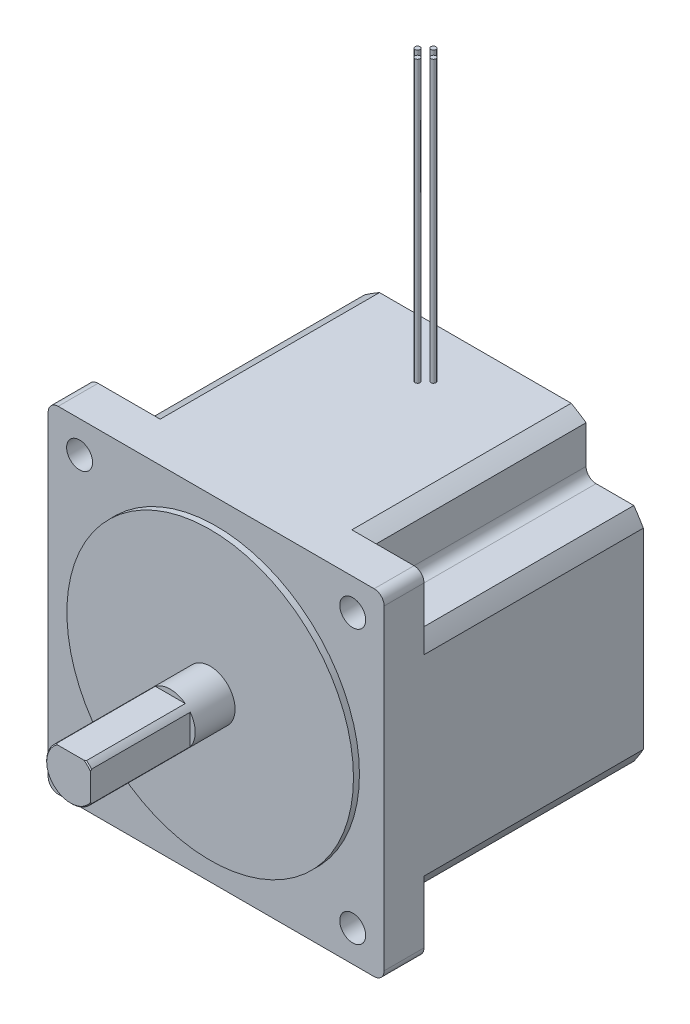
from build123d import *

# Parameters (mm, degrees)
SKETCH1_W           = 85.598
SKETCH1_H           = 85.598
BOSS_EXTRUDE1_DEPTH = 66.04
CUT_EXTRUDE1_DEPTH  = 55.88
CUT_EXTRUDE2_DEPTH  = 55.88
CUT_EXTRUDE3_DEPTH  = 55.88
CUT_EXTRUDE4_DEPTH  = 55.88
CUT_EXTRUDE5_DEPTH  = 55.88
CUT_EXTRUDE6_DEPTH  = 55.88
CUT_EXTRUDE7_DEPTH  = 55.88
CUT_EXTRUDE8_DEPTH  = 55.88
SKETCH10_R          = 36.5125
BOSS_EXTRUDE2_DEPTH = 1.524
SKETCH11_R          = 6.35
BOSS_EXTRUDE3_DEPTH = 35.56
CUT_EXTRUDE9_DEPTH  = 25.4
CUT_EXTRUDE10_DEPTH = 25.4
SKETCH14_W          = 0.635
SKETCH14_H          = 71.501
SKETCH15_W          = 0.635
SKETCH15_H          = 71.501
SKETCH16_W          = 0.635
SKETCH16_H          = 71.501
SKETCH17_W          = 0.635
SKETCH17_H          = 71.501
HOLE1_D             = 6.604
HOLE1_DEPTH         = 47.244
HOLE2_D             = 6.604
HOLE2_DEPTH         = 47.244
HOLE3_D             = 6.604
HOLE3_DEPTH         = 47.244
HOLE4_D             = 6.604
HOLE4_DEPTH         = 47.244
CHAMFER1_SIZE       = 0.254
CHAMFER2_SIZE       = 0.254
FILLET1_R           = 2.54
FILLET2_R           = 2.54
FILLET3_R           = 2.54
FILLET4_R           = 2.54
FILLET5_R           = 2.54
FILLET6_R           = 2.54
FILLET7_R           = 2.54
FILLET8_R           = 2.54


with BuildPart() as part:
    # Sketch1 → Boss-Extrude1 (new body)
    with BuildSketch(Plane.XY.offset(66.04)):
        Rectangle(SKETCH1_W, SKETCH1_H)
    extrude(amount=-BOSS_EXTRUDE1_DEPTH)

    # Sketch2 → Cut-Extrude1 (cut)
    with BuildSketch(Plane(origin=(0, 0, 0), x_dir=(-1, 0, 0), z_dir=(0, 0, -1))):
        with BuildLine():
            Line((-42.799, -42.799), (-24.420683344, -42.799))
            ThreePointArc((-24.420683344, -42.799), (-34.84339375, -34.84339375), (-42.799, -24.420683344))
            Line((-42.799, -24.420683344), (-42.799, -42.799))
        make_face()
    extrude(amount=-CUT_EXTRUDE1_DEPTH, mode=Mode.SUBTRACT)

    # Sketch3 → Cut-Extrude2 (cut)
    with BuildSketch(Plane(origin=(0, 0, 0), x_dir=(-1, 0, 0), z_dir=(0, 0, -1))):
        with BuildLine():
            Line((-28.2194, -40.395416072), (-28.2194, -28.2194))
            Line((-28.2194, -28.2194), (-40.395416072, -28.2194))
            ThreePointArc((-40.395416072, -28.2194), (-34.84339375, -34.84339375), (-28.2194, -40.395416072))
        make_face()
    extrude(amount=-CUT_EXTRUDE2_DEPTH, mode=Mode.SUBTRACT)

    # Sketch4 → Cut-Extrude3 (cut)
    with BuildSketch(Plane(origin=(0, 0, 0), x_dir=(-1, 0, 0), z_dir=(0, 0, -1))):
        with BuildLine():
            Line((-42.799, 42.799), (-42.799, 24.420683344))
            ThreePointArc((-42.799, 24.420683344), (-34.84339375, 34.84339375), (-24.420683344, 42.799))
            Line((-24.420683344, 42.799), (-42.799, 42.799))
        make_face()
    extrude(amount=-CUT_EXTRUDE3_DEPTH, mode=Mode.SUBTRACT)

    # Sketch5 → Cut-Extrude4 (cut)
    with BuildSketch(Plane(origin=(0, 0, 0), x_dir=(-1, 0, 0), z_dir=(0, 0, -1))):
        with BuildLine():
            Line((-40.395416072, 28.2194), (-28.2194, 28.2194))
            Line((-28.2194, 28.2194), (-28.2194, 40.395416072))
            ThreePointArc((-28.2194, 40.395416072), (-34.84339375, 34.84339375), (-40.395416072, 28.2194))
        make_face()
    extrude(amount=-CUT_EXTRUDE4_DEPTH, mode=Mode.SUBTRACT)

    # Sketch6 → Cut-Extrude5 (cut)
    with BuildSketch(Plane(origin=(0, 0, 0), x_dir=(-1, 0, 0), z_dir=(0, 0, -1))):
        with BuildLine():
            Line((42.799, 42.799), (24.420683344, 42.799))
            ThreePointArc((24.420683344, 42.799), (34.84339375, 34.84339375), (42.799, 24.420683344))
            Line((42.799, 24.420683344), (42.799, 42.799))
        make_face()
    extrude(amount=-CUT_EXTRUDE5_DEPTH, mode=Mode.SUBTRACT)

    # Sketch7 → Cut-Extrude6 (cut)
    with BuildSketch(Plane(origin=(0, 0, 0), x_dir=(-1, 0, 0), z_dir=(0, 0, -1))):
        with BuildLine():
            Line((28.2194, 40.395416072), (28.2194, 28.2194))
            Line((28.2194, 28.2194), (40.395416072, 28.2194))
            ThreePointArc((40.395416072, 28.2194), (34.84339375, 34.84339375), (28.2194, 40.395416072))
        make_face()
    extrude(amount=-CUT_EXTRUDE6_DEPTH, mode=Mode.SUBTRACT)

    # Sketch8 → Cut-Extrude7 (cut)
    with BuildSketch(Plane(origin=(0, 0, 0), x_dir=(-1, 0, 0), z_dir=(0, 0, -1))):
        with BuildLine():
            Line((42.799, -42.799), (42.799, -24.420683344))
            ThreePointArc((42.799, -24.420683344), (34.84339375, -34.84339375), (24.420683344, -42.799))
            Line((24.420683344, -42.799), (42.799, -42.799))
        make_face()
    extrude(amount=-CUT_EXTRUDE7_DEPTH, mode=Mode.SUBTRACT)

    # Sketch9 → Cut-Extrude8 (cut)
    with BuildSketch(Plane(origin=(0, 0, 0), x_dir=(-1, 0, 0), z_dir=(0, 0, -1))):
        with BuildLine():
            Line((40.395416072, -28.2194), (28.2194, -28.2194))
            Line((28.2194, -28.2194), (28.2194, -40.395416072))
            ThreePointArc((28.2194, -40.395416072), (34.84339375, -34.84339375), (40.395416072, -28.2194))
        make_face()
    extrude(amount=-CUT_EXTRUDE8_DEPTH, mode=Mode.SUBTRACT)

    # Sketch10 → Boss-Extrude2 (add)
    with BuildSketch(Plane.XY.offset(66.04)):
        Circle(SKETCH10_R)
    extrude(amount=BOSS_EXTRUDE2_DEPTH)

    # Sketch11 → Boss-Extrude3 (add)
    with BuildSketch(Plane.XY.offset(67.564)):
        Circle(SKETCH11_R)
    extrude(amount=BOSS_EXTRUDE3_DEPTH)

    # Sketch12 → Cut-Extrude9 (cut)
    with BuildSketch(Plane.XY.offset(103.124)):
        with BuildLine():
            Line((-3.81, 5.08), (3.81, 5.08))
            ThreePointArc((3.81, 5.08), (0, 6.35), (-3.81, 5.08))
        make_face()
    extrude(amount=-CUT_EXTRUDE9_DEPTH, mode=Mode.SUBTRACT)

    # Sketch13 → Cut-Extrude10 (cut)
    with BuildSketch(Plane.XY.offset(103.124)):
        with BuildLine():
            Line((5.08, 3.81), (5.08, -3.81))
            ThreePointArc((5.08, -3.81), (6.35, 0), (5.08, 3.81))
        make_face()
    extrude(amount=-CUT_EXTRUDE10_DEPTH, mode=Mode.SUBTRACT)

    # Sketch14 → Revolve1 (revolve)
    with BuildSketch(Plane(origin=(0, 0, 12.7), x_dir=(-1, 0, 0), z_dir=(0, 0, -1))):
        with Locations((1.7145, 78.5495)):
            Rectangle(SKETCH14_W, SKETCH14_H)
    revolve(axis=Axis((-2.032, 42.799, 12.7), (0, 1, 0)))

    # Sketch15 → Revolve2 (revolve)
    with BuildSketch(Plane(origin=(0, 0, 12.7), x_dir=(-1, 0, 0), z_dir=(0, 0, -1))):
        with Locations((-2.3495, 78.5495)):
            Rectangle(SKETCH15_W, SKETCH15_H)
    revolve(axis=Axis((2.032, 42.799, 12.7), (0, 1, 0)))

    # Sketch16 → Revolve3 (revolve)
    with BuildSketch(Plane(origin=(0, 0, 14.732), x_dir=(-1, 0, 0), z_dir=(0, 0, -1))):
        with Locations((-0.3175, 78.5495)):
            Rectangle(SKETCH16_W, SKETCH16_H)
    revolve(axis=Axis((0, 42.799, 14.732), (0, 1, 0)))

    # Sketch17 → Revolve4 (revolve)
    with BuildSketch(Plane(origin=(0, 0, 10.668), x_dir=(-1, 0, 0), z_dir=(0, 0, -1))):
        with Locations((-0.3175, 78.5495)):
            Rectangle(SKETCH17_W, SKETCH17_H)
    revolve(axis=Axis((0, 42.799, 10.668), (0, 1, 0)))

    # Hole1
    with Locations(Plane(origin=(0, 0, 55.88), x_dir=(-1, 0, 0), z_dir=(0, 0, -1))):
        with Locations((34.798, -34.798)):
            Hole(HOLE1_D / 2, depth=HOLE1_DEPTH)

    # Hole2
    with Locations(Plane(origin=(0, 0, 55.88), x_dir=(-1, 0, 0), z_dir=(0, 0, -1))):
        with Locations((34.798, 34.798)):
            Hole(HOLE2_D / 2, depth=HOLE2_DEPTH)

    # Hole3
    with Locations(Plane(origin=(0, 0, 55.88), x_dir=(-1, 0, 0), z_dir=(0, 0, -1))):
        with Locations((-34.798, 34.798)):
            Hole(HOLE3_D / 2, depth=HOLE3_DEPTH)

    # Hole4
    with Locations(Plane(origin=(0, 0, 55.88), x_dir=(-1, 0, 0), z_dir=(0, 0, -1))):
        with Locations((-34.798, -34.798)):
            Hole(HOLE4_D / 2, depth=HOLE4_DEPTH)

    # Chamfer1
    chamfer1_edges = [part.edges().sort_by_distance(p)[0] for p in [
        (-4.490128061, -4.490128061, 103.124),
    ]]
    chamfer(chamfer1_edges, length=CHAMFER1_SIZE)

    # Chamfer2
    chamfer2_edges = [part.edges().sort_by_distance(p)[0] for p in [
        (4.490128061, 4.490128061, 103.124),
    ]]
    chamfer(chamfer2_edges, length=CHAMFER2_SIZE)

    # Fillet1
    fillet1_edges = [part.edges().sort_by_distance(p)[0] for p in [
        (-42.799, -42.799, 60.96),
    ]]
    fillet(fillet1_edges, radius=FILLET1_R)

    # Fillet2
    fillet2_edges = [part.edges().sort_by_distance(p)[0] for p in [
        (-42.799, 42.799, 60.96),
    ]]
    fillet(fillet2_edges, radius=FILLET2_R)

    # Fillet3
    fillet3_edges = [part.edges().sort_by_distance(p)[0] for p in [
        (42.799, 42.799, 60.96),
    ]]
    fillet(fillet3_edges, radius=FILLET3_R)

    # Fillet4
    fillet4_edges = [part.edges().sort_by_distance(p)[0] for p in [
        (-28.2194, 28.2194, 27.94),
    ]]
    fillet(fillet4_edges, radius=FILLET4_R)

    # Fillet5
    fillet5_edges = [part.edges().sort_by_distance(p)[0] for p in [
        (42.799, -42.799, 60.96),
    ]]
    fillet(fillet5_edges, radius=FILLET5_R)

    # Fillet6
    fillet6_edges = [part.edges().sort_by_distance(p)[0] for p in [
        (28.2194, -28.2194, 27.94),
    ]]
    fillet(fillet6_edges, radius=FILLET6_R)

    # Fillet7
    fillet7_edges = [part.edges().sort_by_distance(p)[0] for p in [
        (28.2194, 28.2194, 27.94),
    ]]
    fillet(fillet7_edges, radius=FILLET7_R)

    # Fillet8
    fillet8_edges = [part.edges().sort_by_distance(p)[0] for p in [
        (-28.2194, -28.2194, 27.94),
    ]]
    fillet(fillet8_edges, radius=FILLET8_R)


solid = part.part
